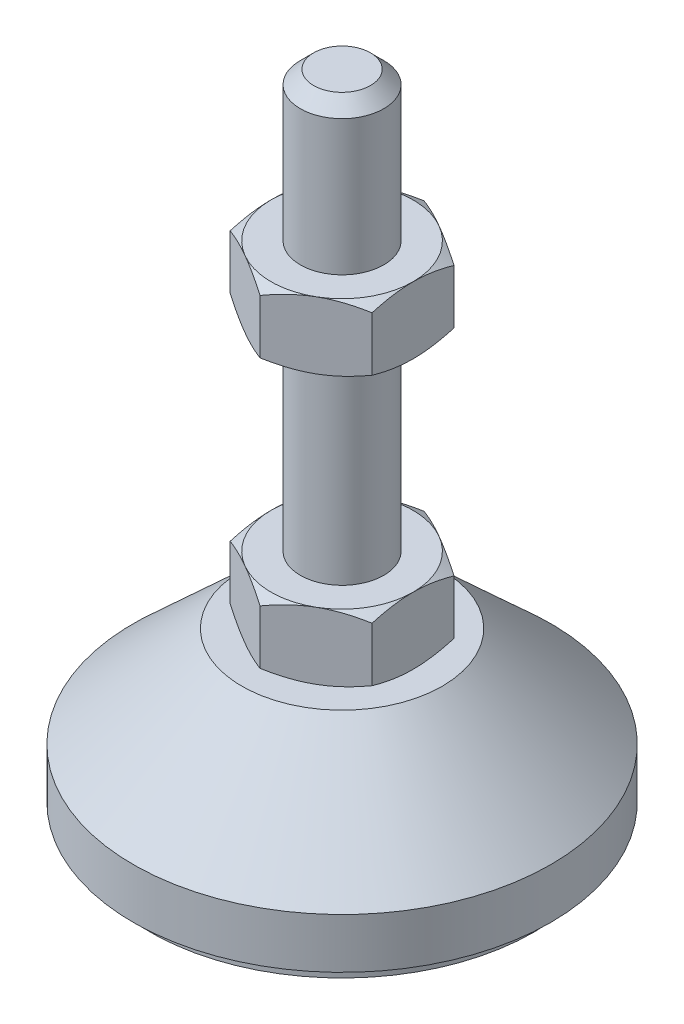
from build123d import *

# Parameters (mm, degrees)
EXTRUDE_1_DEPTH = 8
EXTRUDE_2_DEPTH = 8


with BuildPart() as part:
    # Эскиз1 → Повернуть1 (revolve)
    with BuildSketch(Plane.XY, mode=Mode.PRIVATE) as revolve_1_sk:
        Polygon((0, 0), (-23, 0), (-23, 2), (-25, 2), (-25, 8), (-12, 20), (-5, 20), (-5, 28), (-5, 76.4), (-3.4, 78), (0, 78), align=None)
    revolve(revolve_1_sk.sketch.rotate(Axis((0, 0, 0), (0, 1, 0)), 180), axis=Axis((0, 0, 0), (0, 1, 0)))  # turned: the seam where the file's is

    # Эскиз2 → Бобышка-Вытянуть1 (add)
    with BuildSketch(Plane(origin=(0, 20, 0), x_dir=(1, 0, 0), z_dir=(0, 1, 0))):
        Polygon((0, 9.814954576), (-8.5, 4.907477288), (-8.5, -4.907477288), (0, -9.814954576), (8.5, -4.907477288), (8.5, 4.907477288), align=None)
    extrude(amount=EXTRUDE_1_DEPTH)

    # Эскиз3 → Бобышка-Вытянуть2 (add)
    with BuildSketch(Plane(origin=(0, 52.2, 0), x_dir=(1, 0, 0), z_dir=(0, 1, 0))):
        Polygon((8.5, 4.907477288), (0, 9.814954576), (-8.5, 4.907477288), (-8.5, -4.907477288), (0, -9.814954576), (8.5, -4.907477288), align=None)
    extrude(amount=EXTRUDE_2_DEPTH)

    # Эскиз4 → Вырез-Повернуть2 (revolve, cut)
    with BuildSketch(Plane.XY, mode=Mode.PRIVATE) as cut_revolve_2_sk:
        Polygon((-15.42820323, 60.2), (-8.5, 60.2), (-15.42820323, 56.2), align=None)
        Polygon((-15.42820323, 52.2), (-15.42820323, 56.2), (-8.5, 52.2), align=None)
        Polygon((-15.42820323, 28), (-15.42820323, 24), (-8.5, 28), align=None)
        Polygon((-15.42820323, 24), (-15.42820323, 20), (-8.5, 20), align=None)
    revolve(cut_revolve_2_sk.sketch.rotate(Axis((0, 78, 0), (0, 1, 0)), 180), axis=Axis((0, 78, 0), (0, 1, 0)), mode=Mode.SUBTRACT)  # turned: the seam where the file's is


solid = part.part
